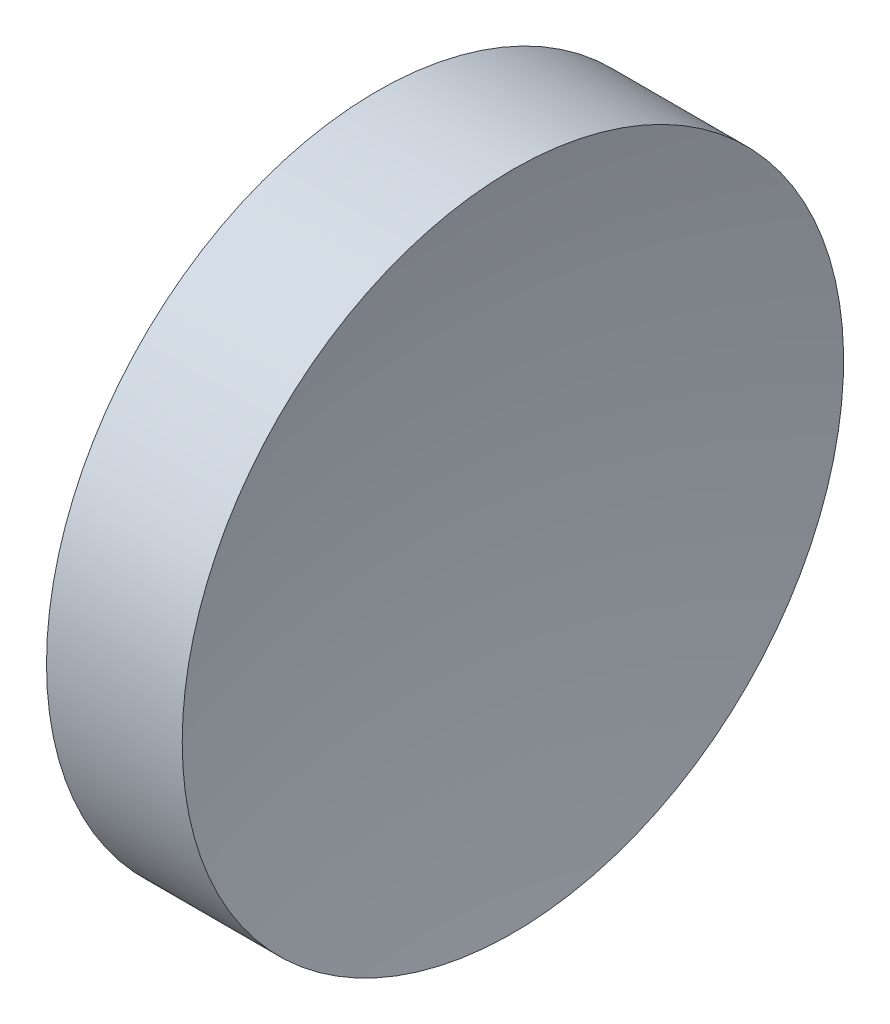
from build123d import *


with BuildPart() as part:
    # 草图1 → 旋转1 (revolve)
    with BuildSketch(Plane.XY):
        with BuildLine():
            Line((47.701711212, 28.477595635), (47.701711212, 33.477595635))
            Line((47.701711212, 33.477595635), (49.753734102, 33.477595635))
            ThreePointArc((49.753734102, 33.477595635), (49.340134935, 30.992785949), (49.201711212, 28.477595635))
            Line((49.201711212, 28.477595635), (47.701711212, 28.477595635))
        make_face()
    revolve(axis=Axis((44.782091903, 28.477595635, 0), (1, 0, 0)))


solid = part.part
